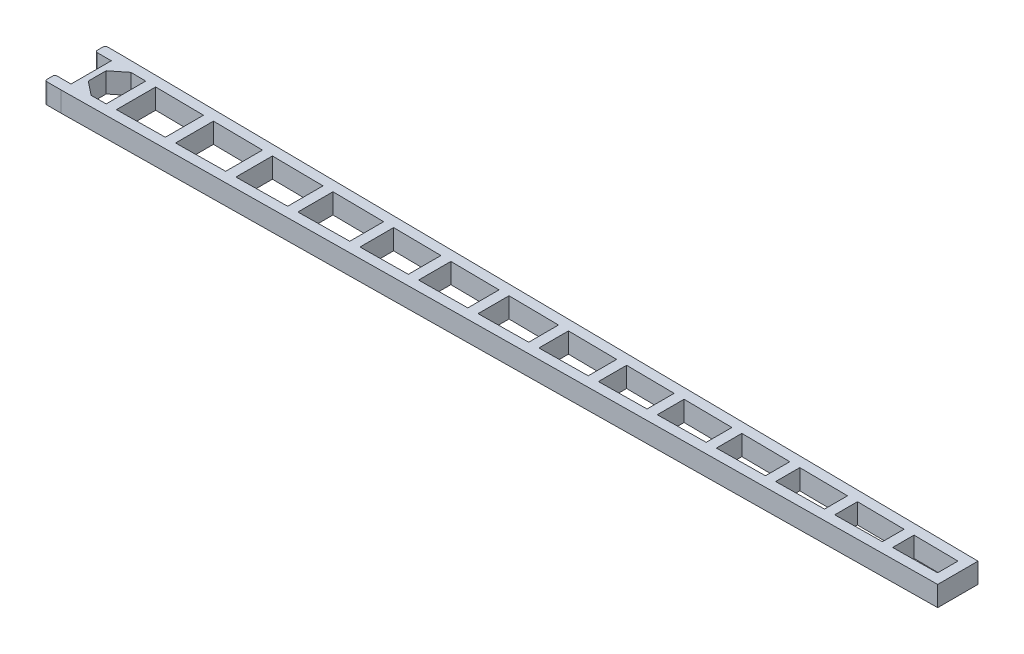
from build123d import *

# Parameters (mm, degrees)
SALIENTE_EXTRUIR2_DEPTH = 10
ESCALA1_SCALE           = 0.5


with BuildPart() as part:
    # Croquis1 → Saliente-Extruir2 (new body)
    with BuildSketch(Plane(origin=(0, 0, 0), x_dir=(1, 0, 0), z_dir=(0, 1, 0))):
        with BuildLine():
            Line((347.768463119, -7.519240019), (347.768463119, 12.480759981))
            Line((347.768463119, 12.480759981), (-82.231536881, 17.480759981))
            Line((-82.231536881, 17.480759981), (-89.231536881, 17.480759981))
            ThreePointArc((-89.231536881, 17.480759981), (-89.938643662, 17.187866762), (-90.231536881, 16.480759981))
            Line((-90.231536881, 16.480759981), (-90.231536881, 13.480759981))
            ThreePointArc((-90.231536881, 13.480759981), (-89.938643662, 12.7736532), (-89.231536881, 12.480759981))
            Line((-89.231536881, 12.480759981), (-82.231536881, 12.480759981))
            Line((-82.231536881, 12.480759981), (-82.231536881, -7.519240019))
            Line((-82.231536881, -7.519240019), (-89.231536881, -7.519240019))
            ThreePointArc((-89.231536881, -7.519240019), (-89.938643662, -7.812133238), (-90.231536881, -8.519240019))
            Line((-90.231536881, -8.519240019), (-90.231536881, -11.519240019))
            ThreePointArc((-90.231536881, -11.519240019), (-89.938643662, -12.2263468), (-89.231536881, -12.519240019))
            Line((-89.231536881, -12.519240019), (-82.231536881, -12.519240019))
            Line((-82.231536881, -12.519240019), (347.768463119, -7.519240019))
        make_face()
        Polygon((-35.970310827, -6.981318786), (-35.970310827, 11.942838748), (-59.970310827, 12.221908515), (-59.970310827, -7.260388554), align=None, mode=Mode.SUBTRACT)
        Polygon((-6.36676246, -6.637091479), (-6.36676246, 11.598611441), (-30.970310827, 11.884699213), (-30.970310827, -6.923179251), align=None, mode=Mode.SUBTRACT)
        Polygon((24.032508683, -6.283611582), (24.032508683, 11.245131544), (-1.36676246, 11.540471906), (-1.36676246, -6.578951945), align=None, mode=Mode.SUBTRACT)
        Polygon((54.471653082, -5.929668043), (54.471653082, 10.891188004), (29.032508683, 11.186992009), (29.032508683, -6.225472048), align=None, mode=Mode.SUBTRACT)
        Polygon((83.209124846, -5.595511395), (83.209124846, 10.557031356), (59.471653082, 10.83304847), (59.471653082, -5.871528508), align=None, mode=Mode.SUBTRACT)
        Polygon((112.395607474, -5.25613369), (112.395607474, 10.217653651), (88.209124846, 10.498891821), (88.209124846, -5.53737186), align=None, mode=Mode.SUBTRACT)
        Polygon((142.246515855, -4.909030104), (142.246515855, 9.870550065), (117.395607474, 10.159514116), (117.395607474, -5.197994155), align=None, mode=Mode.SUBTRACT)
        Polygon((171.437834583, -4.569596165), (171.437834583, 9.531116127), (147.246515855, 9.81241053), (147.246515855, -4.850890569), align=None, mode=Mode.SUBTRACT)
        Polygon((200.288401316, -4.234124459), (200.288401316, 9.19564442), (176.437834583, 9.472976592), (176.437834583, -4.51145663), align=None, mode=Mode.SUBTRACT)
        Polygon((229.28834427, -3.89691582), (229.28834427, 8.858435781), (205.288401316, 9.137504885), (205.288401316, -4.175984924), align=None, mode=Mode.SUBTRACT)
        Polygon((258.357613703, -3.558901059), (258.357613703, 8.52042102), (234.28834427, 8.800296246), (234.28834427, -3.838776285), align=None, mode=Mode.SUBTRACT)
        Polygon((287.325919365, -3.222060295), (287.325919365, 8.183580257), (263.357613703, 8.462281486), (263.357613703, -3.500761524), align=None, mode=Mode.SUBTRACT)
        Polygon((315.709556101, -2.892018008), (315.709556101, 7.853537969), (292.325919365, 8.125440722), (292.325919365, -3.163920761), align=None, mode=Mode.SUBTRACT)
        Polygon((342.768463119, -2.577379554), (342.768463119, 7.538899516), (320.709556101, 7.795398434), (320.709556101, -2.833878473), align=None, mode=Mode.SUBTRACT)
        Polygon((-64.970310827, -7.318528088), (-64.970310827, 12.28004805), (-72.387230354, 12.3662913), (-79.231536881, 6.910670608), (-79.231536881, -1.949150646), (-72.387230358, -7.404771339), align=None, mode=Mode.SUBTRACT)
    extrude(amount=SALIENTE_EXTRUIR2_DEPTH)


with BuildPart() as part_1:
    # Escala1: scaled about (123.080377325, 5, -2.480759981)
    add(part.part.scale(ESCALA1_SCALE).moved(Location((61.540188663, 2.5, -1.24037999))))


solid = part_1.part
